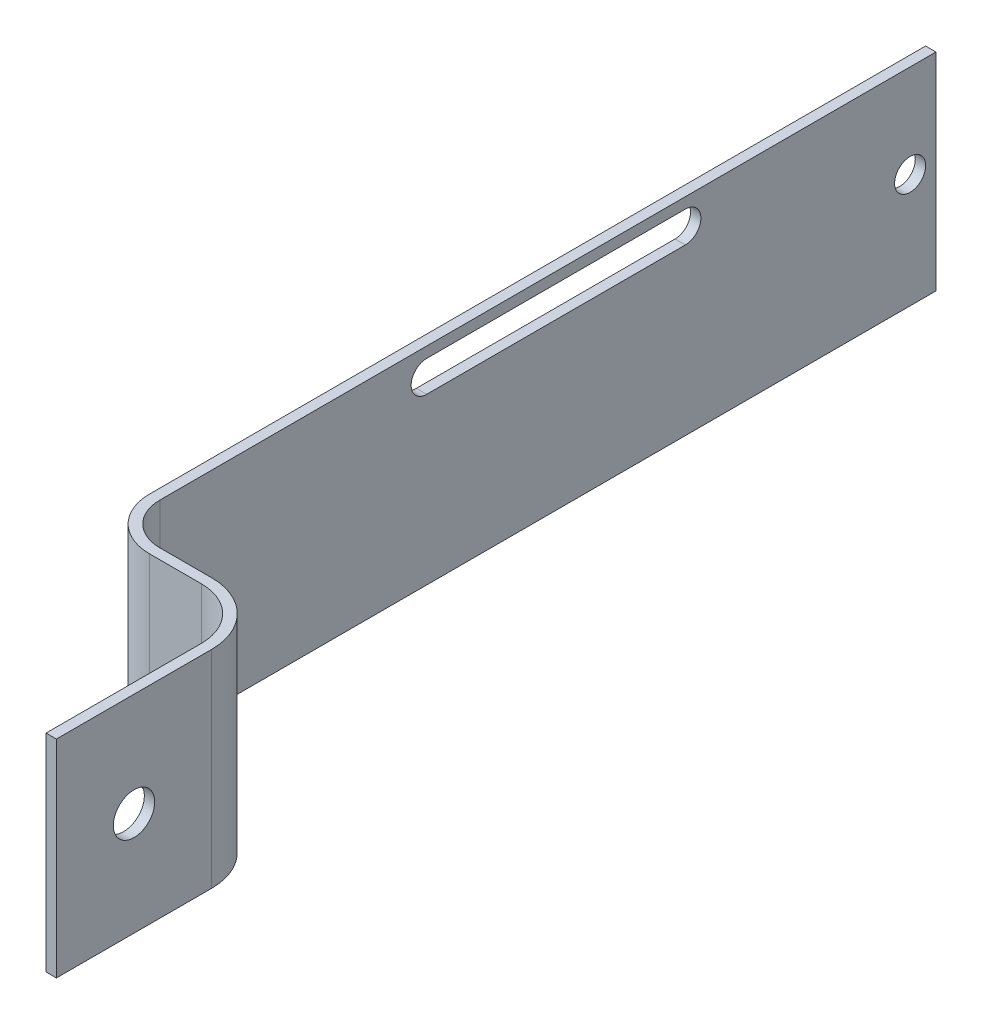
from build123d import *

# Parameters (mm, degrees)
EXTRUDE_THIN1_DEPTH = 20
SKETCH2_R           = 2
CUT_EXTRUDE1_DEPTH  = 17
SKETCH3_R           = 1.5
CUT_EXTRUDE2_DEPTH  = 2
CUT_EXTRUDE3_DEPTH  = 17


with BuildPart() as part:
    # Sketch1 → Extrude-Thin1 (new body)
    with BuildSketch(Plane(origin=(0, 0, 0), x_dir=(1, 0, 0), z_dir=(0, 1, 0))):
        with BuildLine():
            Line((0, 0), (0, 15))
            ThreePointArc((0, 15), (-1.464466094, 18.535533906), (-5, 20))
            Line((-5, 20), (-10, 20))
            ThreePointArc((-10, 20), (-13.535533906, 21.464466094), (-15, 25))
            Line((-15, 25), (-15, 100))
            Line((-15, 100), (-14, 100))
            Line((-14, 100), (-14, 25))
            ThreePointArc((-14, 25), (-12.828427125, 22.171572875), (-10, 21))
            Line((-10, 21), (-5, 21))
            ThreePointArc((-5, 21), (-0.757359313, 19.242640687), (1, 15))
            Line((1, 15), (1, 0))
            Line((1, 0), (0, 0))
        make_face()
    extrude(amount=EXTRUDE_THIN1_DEPTH)

    # Sketch2 → Cut-Extrude1 (cut, through all)
    with BuildSketch(Plane(origin=(1, 0, 0), x_dir=(0, 0, -1), z_dir=(1, 0, 0))):
        with Locations((7.5, 10)):
            Circle(SKETCH2_R)
    extrude(amount=-CUT_EXTRUDE1_DEPTH, mode=Mode.SUBTRACT)

    # Sketch3 → Cut-Extrude2 (cut, through all)
    with BuildSketch(Plane(origin=(-14, 0, 0), x_dir=(0, 0, -1), z_dir=(1, 0, 0))):
        with Locations((97.5, 11)):
            Circle(SKETCH3_R)
    extrude(amount=-CUT_EXTRUDE2_DEPTH, mode=Mode.SUBTRACT)

    # Sketch4 → Cut-Extrude3 (cut, through all)
    with BuildSketch(Plane.ZY.offset(15)):
        with BuildLine():
            Line((-50.783321534, 18.959123293), (-75.783321534, 18.959123293))
            ThreePointArc((-75.783321534, 18.959123293), (-77.283321534, 17.459123293), (-75.783321534, 15.959123293))
            Line((-75.783321534, 15.959123293), (-50.783321534, 15.959123293))
            ThreePointArc((-50.783321534, 15.959123293), (-49.283321534, 17.459123293), (-50.783321534, 18.959123293))
        make_face()
    extrude(amount=-CUT_EXTRUDE3_DEPTH, mode=Mode.SUBTRACT)


solid = part.part
